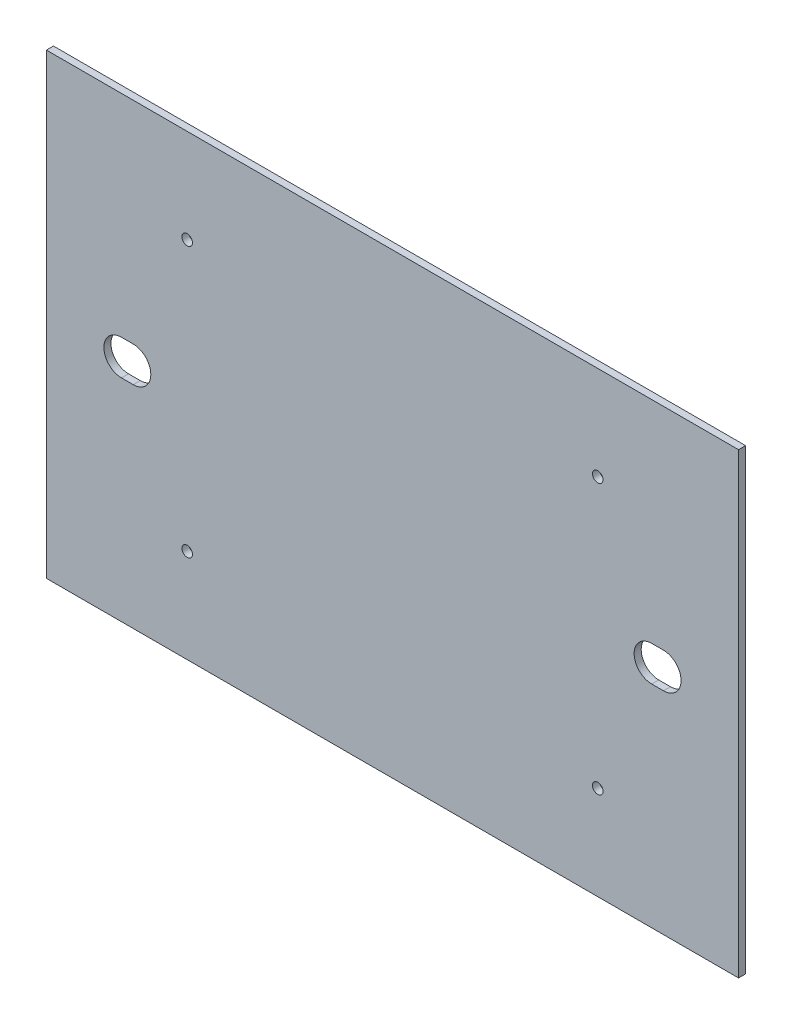
from build123d import *

# Parameters (mm, degrees)
ESQUISSE1_W        = 295
ESQUISSE1_H        = 195
ESQUISSE1_R        = 2.25
BOSS_EXTRU_1_DEPTH = 3


with BuildPart() as part:
    # Esquisse1 → Boss.-Extru.1 (new body)
    with BuildSketch(Plane.XY):
        with Locations((147.5, -97.5)):
            Rectangle(ESQUISSE1_W, ESQUISSE1_H)
        with Locations((60, -40)):
            Circle(ESQUISSE1_R, mode=Mode.SUBTRACT)
        with Locations((235, -40)):
            Circle(ESQUISSE1_R, mode=Mode.SUBTRACT)
        with Locations((235, -155)):
            Circle(ESQUISSE1_R, mode=Mode.SUBTRACT)
        with Locations((60, -155)):
            Circle(ESQUISSE1_R, mode=Mode.SUBTRACT)
        with BuildLine():
            Line((32, -90), (37, -90))
            ThreePointArc((37, -90), (44.5, -97.5), (37, -105))
            Line((37, -105), (32, -105))
            ThreePointArc((32, -105), (24.5, -97.5), (32, -90))
        make_face(mode=Mode.SUBTRACT)
        with BuildLine():
            Line((263, -105), (258, -105))
            ThreePointArc((258, -105), (250.5, -97.5), (258, -90))
            Line((258, -90), (263, -90))
            ThreePointArc((263, -90), (270.5, -97.5), (263, -105))
        make_face(mode=Mode.SUBTRACT)
    extrude(amount=BOSS_EXTRU_1_DEPTH)


solid = part.part
